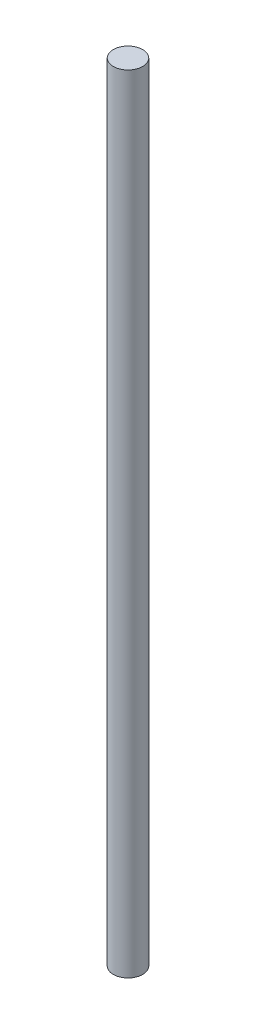
from build123d import *

# Parameters (mm, degrees)
SKETCH1_R           = 6
BOSS_EXTRUDE1_DEPTH = 321


with BuildPart() as part:
    # Sketch1 → Boss-Extrude1 (new body)
    with BuildSketch(Plane(origin=(0, 0, 0), x_dir=(1, 0, 0), z_dir=(0, 1, 0))):
        Circle(SKETCH1_R)
    extrude(amount=BOSS_EXTRUDE1_DEPTH)


solid = part.part
